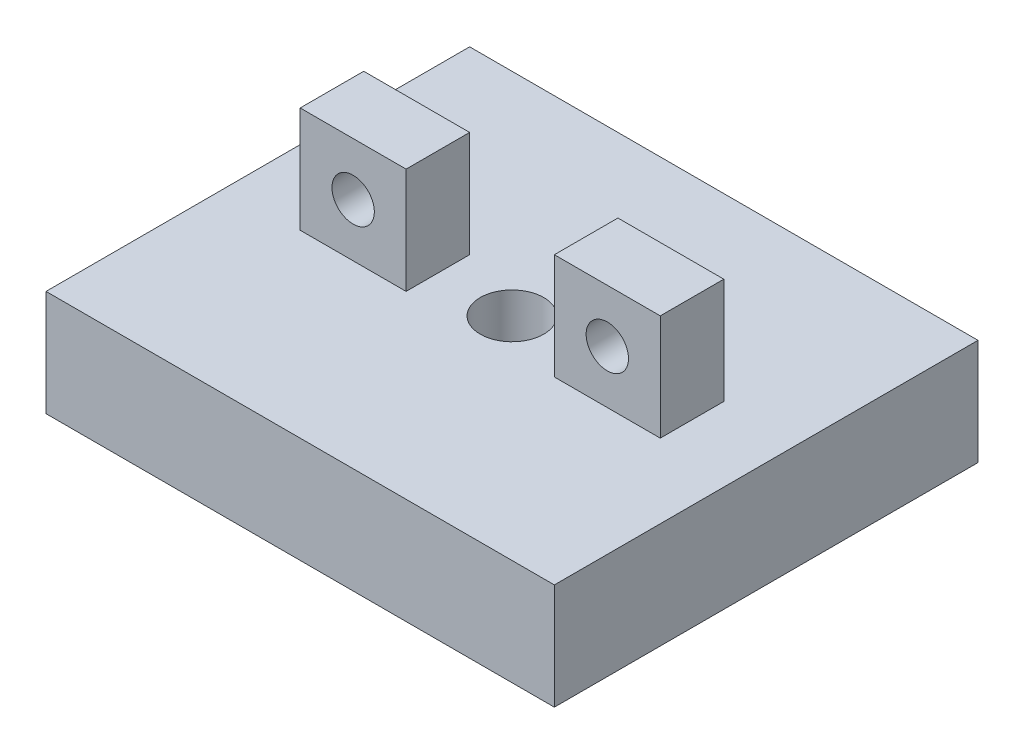
from build123d import *

# Parameters (mm, degrees)
SKETCH2_W           = 24
SKETCH2_H           = 20
BOSS_EXTRUDE1_DEPTH = 5
SKETCH3_W           = 5
SKETCH3_H           = 3
BOSS_EXTRUDE2_DEPTH = 5
SKETCH5_R           = 1
CUT_EXTRUDE2_DEPTH  = 3
SKETCH6_R           = 1
CUT_EXTRUDE3_DEPTH  = 3
SKETCH7_R           = 1.5
CUT_EXTRUDE4_DEPTH  = 5


with BuildPart() as part:
    # Sketch2 → Boss-Extrude1 (new body)
    with BuildSketch(Plane(origin=(0, 0, 0), x_dir=(1, 0, 0), z_dir=(0, 1, 0))):
        with Locations((-18.771651872, -1.433503677)):
            Rectangle(SKETCH2_W, SKETCH2_H)
    extrude(amount=BOSS_EXTRUDE1_DEPTH)

    # Sketch3 → Boss-Extrude2 (add)
    with BuildSketch(Plane(origin=(0, 5, 0), x_dir=(1, 0, 0), z_dir=(0, 1, 0))):
        with Locations((-12.771651872, -1.433503677)):
            Rectangle(SKETCH3_W, SKETCH3_H)
        with Locations((-24.771651872, -1.433503677)):
            Rectangle(SKETCH3_W, SKETCH3_H)
    extrude(amount=BOSS_EXTRUDE2_DEPTH)

    # Sketch5 → Cut-Extrude2 (cut)
    with BuildSketch(Plane(origin=(0, 0, -0.066496323), x_dir=(-1, 0, 0), z_dir=(0, 0, -1))):
        with Locations((12.771651872, 7.5)):
            Circle(SKETCH5_R)
    extrude(amount=-CUT_EXTRUDE2_DEPTH, mode=Mode.SUBTRACT)

    # Sketch6 → Cut-Extrude3 (cut)
    with BuildSketch(Plane(origin=(0, 0, -0.066496323), x_dir=(-1, 0, 0), z_dir=(0, 0, -1))):
        with Locations((24.771651872, 7.5)):
            Circle(SKETCH6_R)
    extrude(amount=-CUT_EXTRUDE3_DEPTH, mode=Mode.SUBTRACT)

    # Sketch7 → Cut-Extrude4 (cut)
    with BuildSketch(Plane(origin=(0, 5, 0), x_dir=(1, 0, 0), z_dir=(0, 1, 0))):
        with Locations((-18.771651872, -1.433503677)):
            Circle(SKETCH7_R)
    extrude(amount=-CUT_EXTRUDE4_DEPTH, mode=Mode.SUBTRACT)


solid = part.part
